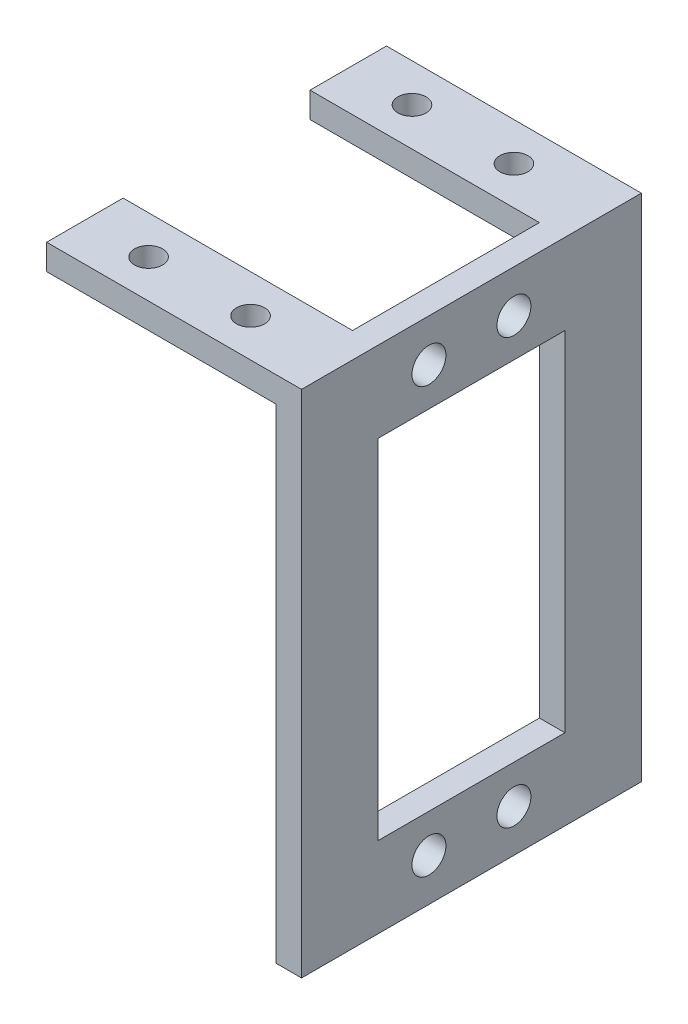
from build123d import *

# Parameters (mm, degrees)
EXTRUDE_1_DEPTH     = 40
SKETCH_2_R          = 1.65
SKETCH_2_W          = 27
SKETCH_2_H          = 22
CUT_EXTRUDE_2_DEPTH = 10
SKETCH_3_R          = 2
SKETCH_3_W          = 22
SKETCH_3_H          = 41
CUT_EXTRUDE_3_DEPTH = 10


with BuildPart() as part:
    # 草图1 → 凸台-拉伸1 (new body)
    with BuildSketch(Plane.XY):
        Polygon((0, 0), (30, 0), (30, -60), (27, -60), (27, -3), (0, -3), align=None)
    extrude(amount=EXTRUDE_1_DEPTH)

    # 草图2 → 切除-拉伸2 (cut)
    with BuildSketch(Plane(origin=(0, 0, 0), x_dir=(1, 0, 0), z_dir=(0, 1, 0))):
        with Locations((7.5, -4.5)):
            Circle(SKETCH_2_R)
        with Locations((19.5, -4.5)):
            Circle(SKETCH_2_R)
        with Locations((19.5, -35.5)):
            Circle(SKETCH_2_R)
        with Locations((7.5, -35.5)):
            Circle(SKETCH_2_R)
        with Locations((13.5, -20)):
            Rectangle(SKETCH_2_W, SKETCH_2_H)
    extrude(amount=-CUT_EXTRUDE_2_DEPTH, mode=Mode.SUBTRACT)

    # 草图3 → 切除-拉伸3 (cut)
    with BuildSketch(Plane(origin=(30, 0, 0), x_dir=(0, 0, -1), z_dir=(1, 0, 0))):
        with Locations((-25, -5)):
            Circle(SKETCH_3_R)
        with Locations((-15, -5)):
            Circle(SKETCH_3_R)
        with Locations((-15, -55)):
            Circle(SKETCH_3_R)
        with Locations((-25, -55)):
            Circle(SKETCH_3_R)
        with Locations((-20, -30)):
            Rectangle(SKETCH_3_W, SKETCH_3_H)
    extrude(amount=-CUT_EXTRUDE_3_DEPTH, mode=Mode.SUBTRACT)


solid = part.part
